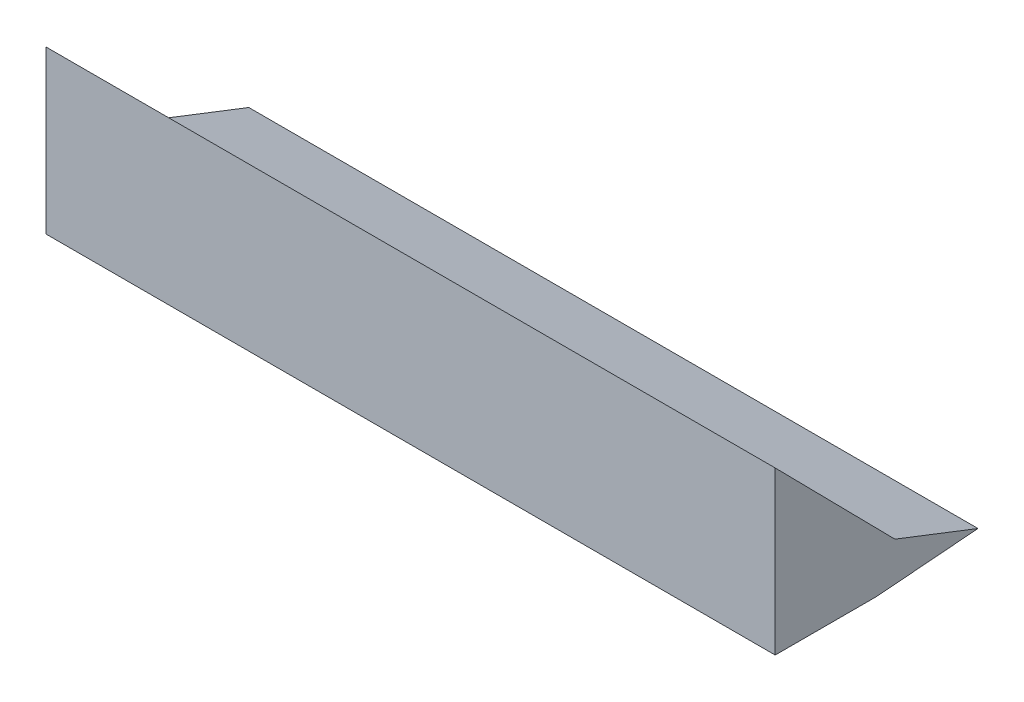
from build123d import *

# Parameters (mm, degrees)
BOSS_EXTRUDE1_DEPTH = 180


with BuildPart() as part:
    # Sketch1 → Boss-Extrude1 (new body)
    with BuildSketch(Plane(origin=(0, 0, 0), x_dir=(0, 0, -1), z_dir=(1, 0, 0))):
        Polygon((0, 0), (0, 40), (29.555448143, 10), (50.060094066, 2.027579065), (25, 0), align=None)
    extrude(amount=BOSS_EXTRUDE1_DEPTH)


solid = part.part
